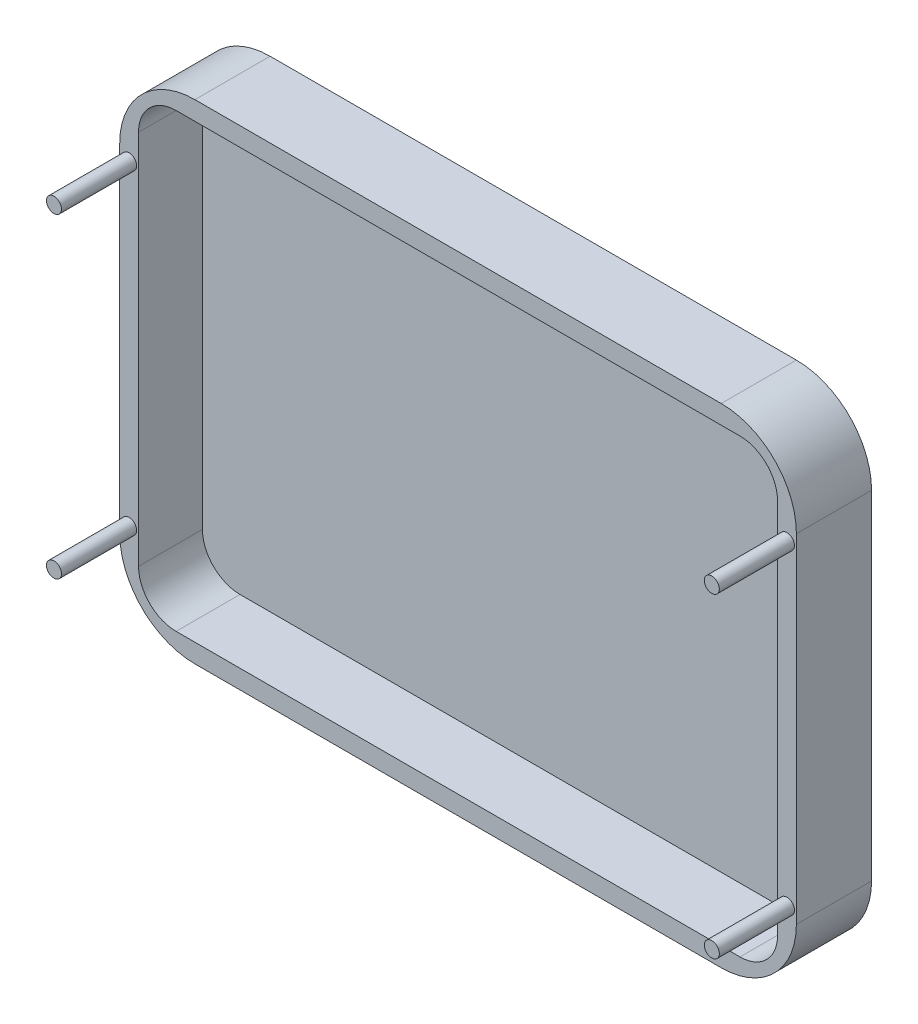
from build123d import *

# Parameters (mm, degrees)
BOSS_EXTRUDE1_DEPTH = 20
CUT_EXTRUDE1_DEPTH  = 17
SKETCH3_R           = 2
BOSS_EXTRUDE3_DEPTH = 20


with BuildPart() as part:
    # Sketch1 → Boss-Extrude1 (new body)
    with BuildSketch(Plane.XY):
        with BuildLine():
            Line((-64.955555556, 61.244444444), (75.044444444, 61.244444444))
            ThreePointArc((75.044444444, 61.244444444), (89.186580068, 55.386580068), (95.044444444, 41.244444444))
            Line((95.044444444, 41.244444444), (95.044444444, -48.755555556))
            ThreePointArc((95.044444444, -48.755555556), (89.186580068, -62.897691179), (75.044444444, -68.755555556))
            Line((75.044444444, -68.755555556), (-64.955555556, -68.755555556))
            ThreePointArc((-64.955555556, -68.755555556), (-79.097691179, -62.897691179), (-84.955555556, -48.755555556))
            Line((-84.955555556, -48.755555556), (-84.955555556, 41.244444444))
            ThreePointArc((-84.955555556, 41.244444444), (-79.097691179, 55.386580068), (-64.955555556, 61.244444444))
        make_face()
    extrude(amount=BOSS_EXTRUDE1_DEPTH)

    # Sketch2 → Cut-Extrude1 (cut)
    with BuildSketch(Plane.XY.offset(20)):
        with BuildLine():
            Line((-69.955555556, 56.244444444), (80.044444444, 56.244444444))
            ThreePointArc((80.044444444, 56.244444444), (87.115512256, 53.315512256), (90.044444444, 46.244444444))
            Line((90.044444444, 46.244444444), (90.044444444, -53.755555556))
            ThreePointArc((90.044444444, -53.755555556), (87.115512256, -60.826623367), (80.044444444, -63.755555556))
            Line((80.044444444, -63.755555556), (-69.955555556, -63.755555556))
            ThreePointArc((-69.955555556, -63.755555556), (-77.026623367, -60.826623367), (-79.955555556, -53.755555556))
            Line((-79.955555556, -53.755555556), (-79.955555556, 46.244444444))
            ThreePointArc((-79.955555556, 46.244444444), (-77.026623367, 53.315512256), (-69.955555556, 56.244444444))
        make_face()
    extrude(amount=-CUT_EXTRUDE1_DEPTH, mode=Mode.SUBTRACT)

    # Sketch3 → Boss-Extrude3 (add)
    with BuildSketch(Plane.XY.offset(20)):
        with Locations((-82.455555556, 38.244444444)):
            Circle(SKETCH3_R)
        with Locations((-82.455555556, -45.755555556)):
            Circle(SKETCH3_R)
        with Locations((92.544444444, -45.755555556)):
            Circle(SKETCH3_R)
        with Locations((92.544444444, 38.244444444)):
            Circle(SKETCH3_R)
    extrude(amount=BOSS_EXTRUDE3_DEPTH)


solid = part.part
